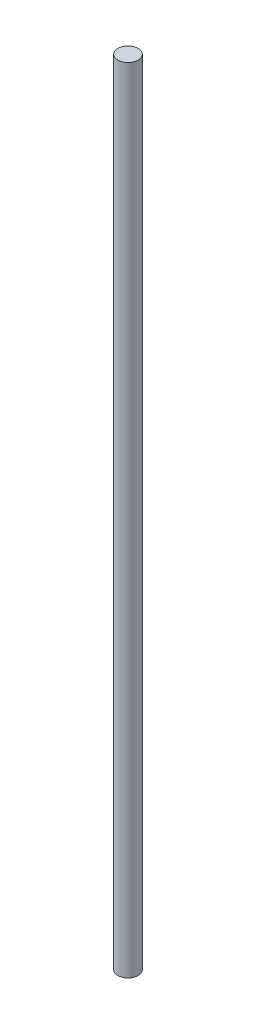
from build123d import *

# Parameters (mm, degrees)
SKETCH1_R           = 3
BOSS_EXTRUDE1_DEPTH = 235


with BuildPart() as part:
    # Sketch1 → Boss-Extrude1 (new body)
    with BuildSketch(Plane(origin=(0, 0, 0), x_dir=(1, 0, 0), z_dir=(0, 1, 0))):
        Circle(SKETCH1_R)
    extrude(amount=BOSS_EXTRUDE1_DEPTH)


solid = part.part
